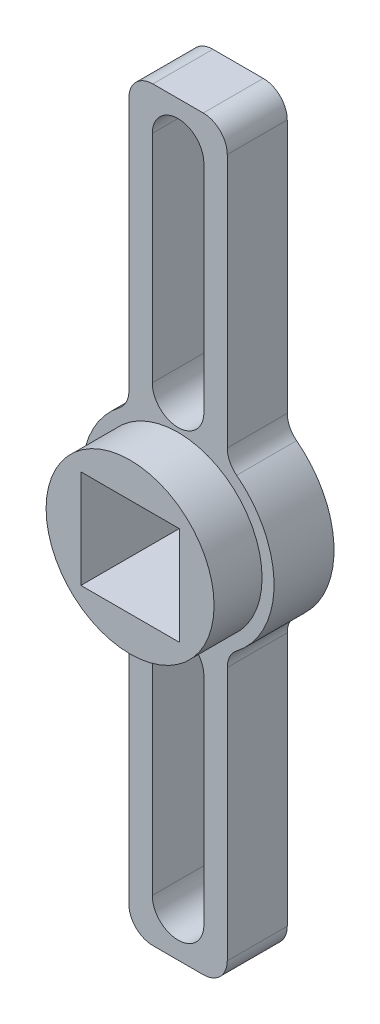
from build123d import *

# Parameters (mm, degrees)
SKETCH_1_R          = 8
SKETCH_1_W          = 8.2
SKETCH_1_H          = 8.2
EXTRUDE_1_DEPTH     = 5
SKETCH_2_W          = 8.2
SKETCH_2_H          = 5
EXTRUDE_2_DEPTH     = 27
SKETCH_3_W          = 8.2
SKETCH_3_H          = 5
EXTRUDE_3_DEPTH     = 27
SKETCH_4_R          = 7
SKETCH_4_W          = 8.2
SKETCH_4_H          = 8.2
EXTRUDE_4_DEPTH     = 4
CUT_EXTRUDE_1_DEPTH = 6
FILLET_1_R          = 2
FILLET_2_R          = 2


with BuildPart() as part:
    # 草图1 → 凸台-拉伸1 (new body)
    with BuildSketch(Plane.XY):
        Circle(SKETCH_1_R)
        Rectangle(SKETCH_1_W, SKETCH_1_H, mode=Mode.SUBTRACT)
    extrude(amount=EXTRUDE_1_DEPTH)

    # 草图2 → 凸台-拉伸2 (add)
    with BuildSketch(Plane.XZ.offset(-4.1)):
        with Locations((0, 2.5)):
            Rectangle(SKETCH_2_W, SKETCH_2_H)
    extrude(amount=-EXTRUDE_2_DEPTH)

    # 草图3 → 凸台-拉伸3 (add)
    with BuildSketch(Plane(origin=(0, -4.1, 0), x_dir=(1, 0, 0), z_dir=(0, 1, 0))):
        with Locations((0, -2.5)):
            Rectangle(SKETCH_3_W, SKETCH_3_H)
    extrude(amount=-EXTRUDE_3_DEPTH)

    # 草图4 → 凸台-拉伸4 (add)
    with BuildSketch(Plane.XY.offset(5)):
        Circle(SKETCH_4_R)
        Rectangle(SKETCH_4_W, SKETCH_4_H, mode=Mode.SUBTRACT)
    extrude(amount=EXTRUDE_4_DEPTH)

    # 草图5 → 切除-拉伸1 (cut, through all)
    with BuildSketch(Plane.XY.offset(5)):
        with BuildLine():
            Line((2.15, 27.5), (2.15, 9.5))
            ThreePointArc((2.15, 9.5), (0, 7.35), (-2.15, 9.5))
            Line((-2.15, 9.5), (-2.15, 27.5))
            ThreePointArc((-2.15, 27.5), (0, 29.65), (2.15, 27.5))
        make_face()
    cut_extrude_1 = extrude(amount=-CUT_EXTRUDE_1_DEPTH, mode=Mode.SUBTRACT)

    # 镜向1: 切除-拉伸1 across plane
    add(cut_extrude_1.mirror(Plane.ZX), mode=Mode.SUBTRACT)

    # 圆角1
    fillet_1_edges = [part.edges().sort_by_distance(p)[0] for p in [
        (-4.1, 6.869497798, 2.5),
        (4.1, 6.869497798, 2.5),
        (4.1, -6.869497798, 2.5),
        (-4.1, -6.869497798, 2.5),
    ]]
    fillet(fillet_1_edges, radius=FILLET_1_R)

    # 圆角2
    fillet_2_edges = [part.edges().sort_by_distance(p)[0] for p in [
        (-4.1, 31.1, 2.5),
        (4.1, 31.1, 2.5),
        (4.1, -31.1, 2.5),
        (-4.1, -31.1, 2.5),
    ]]
    fillet(fillet_2_edges, radius=FILLET_2_R)


solid = part.part
